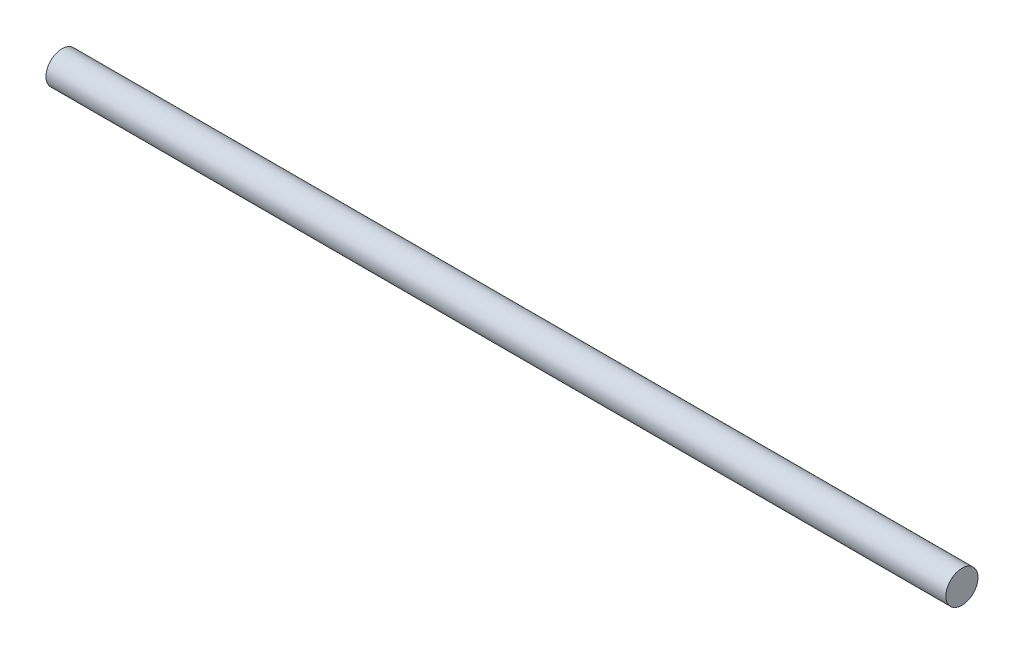
from build123d import *

# Parameters (mm, degrees)
SKETCH1_R           = 3.175
BOSS_EXTRUDE1_DEPTH = 177.8


with BuildPart() as part:
    # Sketch1 → Boss-Extrude1 (new body)
    with BuildSketch(Plane(origin=(0, 0, 0), x_dir=(0, 0, -1), z_dir=(1, 0, 0))):
        Circle(SKETCH1_R)
    extrude(amount=BOSS_EXTRUDE1_DEPTH)


solid = part.part
